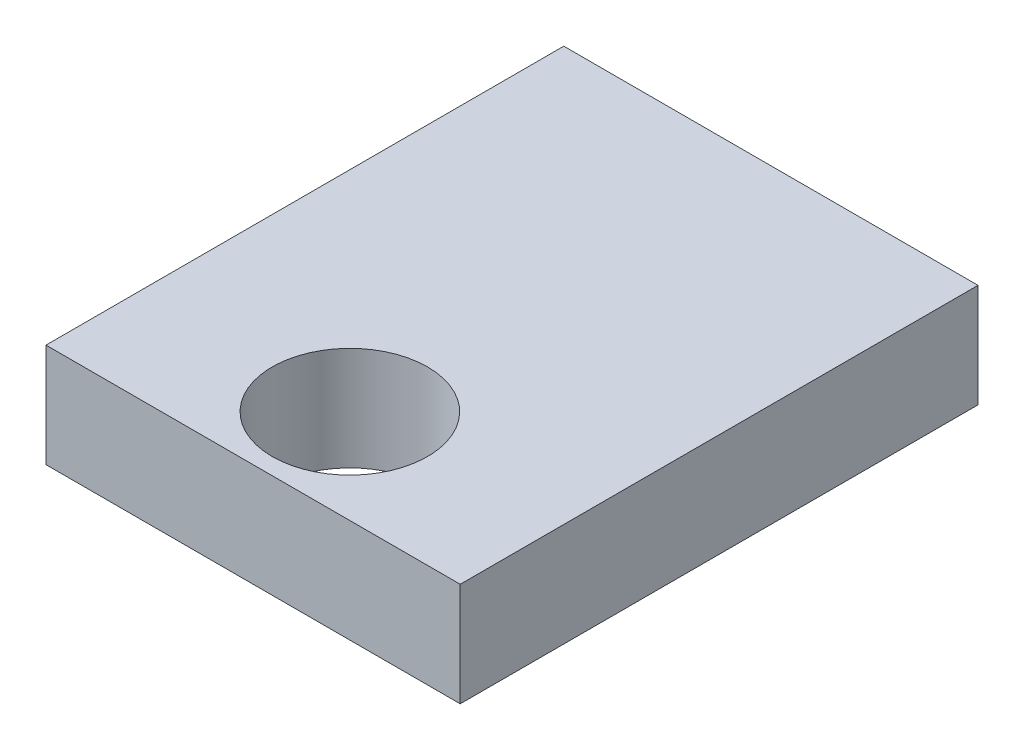
from build123d import *

# Parameters (mm, degrees)
CROQUIS1_W              = 8
CROQUIS1_H              = 10
CROQUIS1_R              = 1.5
SALIENTE_EXTRUIR1_DEPTH = 2
ESCALA1_SCALE           = 7


with BuildPart() as part:
    # Croquis1 → Saliente-Extruir1 (new body)
    with BuildSketch(Plane(origin=(0, 0, 0), x_dir=(1, 0, 0), z_dir=(0, 1, 0))):
        with Locations((4, -5)):
            Rectangle(CROQUIS1_W, CROQUIS1_H)
        with Locations((4.048599745, -8.17997322)):
            Circle(CROQUIS1_R, mode=Mode.SUBTRACT)
    extrude(amount=SALIENTE_EXTRUIR1_DEPTH)


with BuildPart() as part_1:
    # Escala1: scaled about (3.995289666, 1, 4.691793918)
    add(part.part.scale(ESCALA1_SCALE).moved(Location((-23.971737996, -6, -28.150763508))))


solid = part_1.part
